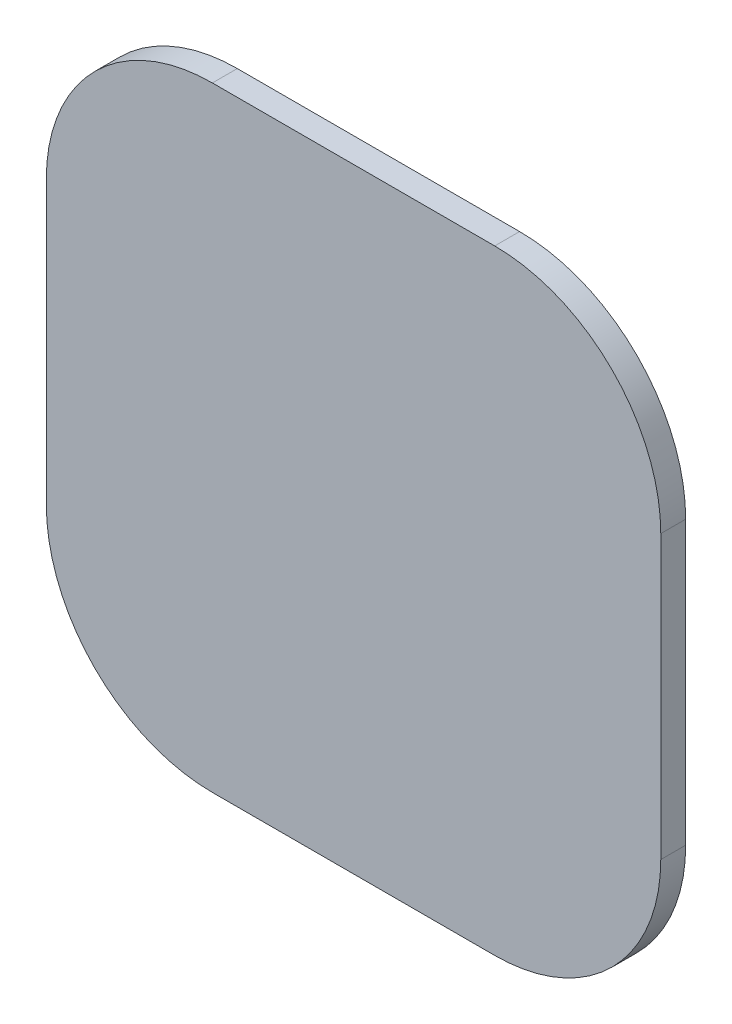
from build123d import *

# Parameters (mm, degrees)
SKETCH_1_W      = 37
SKETCH_1_H      = 37
EXTRUDE_1_DEPTH = 1
SKETCH_1_6_W    = 37
SKETCH_1_6_H    = 37
SKETCH_1_6_R    = 9.05
SKETCH_1_6_R_2  = 9
EXTRUDE_3_DEPTH = 0.5
FILLET_1_R      = 10


with BuildPart() as part:
    # Эскиз1 → Бобышка-Вытянуть1 (new body)
    with BuildSketch(Plane.XY):
        with Locations((9.05, -9.05)):
            Rectangle(SKETCH_1_W, SKETCH_1_H)
    extrude(amount=EXTRUDE_1_DEPTH)

    # Эскиз1<6> → Бобышка-Вытянуть3 (add)
    with BuildSketch(Plane.XY):
        with Locations((9.05, -9.05)):
            Rectangle(SKETCH_1_6_W, SKETCH_1_6_H)
        with Locations((18.1, -18.1)):
            Circle(SKETCH_1_6_R, mode=Mode.SUBTRACT)
        Circle(SKETCH_1_6_R_2, mode=Mode.SUBTRACT)
        with Locations((0, -18.1)):
            Circle(SKETCH_1_6_R_2, mode=Mode.SUBTRACT)
        with Locations((18.1, 0)):
            Circle(SKETCH_1_6_R_2, mode=Mode.SUBTRACT)
    extrude(amount=-EXTRUDE_3_DEPTH)

    # Скругление1
    fillet_1_edges = [part.edges().sort_by_distance(p)[0] for p in [
        (27.55, -27.55, 0.25),
        (27.55, 9.45, 0.25),
        (-9.45, 9.45, 0.25),
        (-9.45, -27.55, 0.25),
    ]]
    fillet(fillet_1_edges, radius=FILLET_1_R)


solid = part.part
